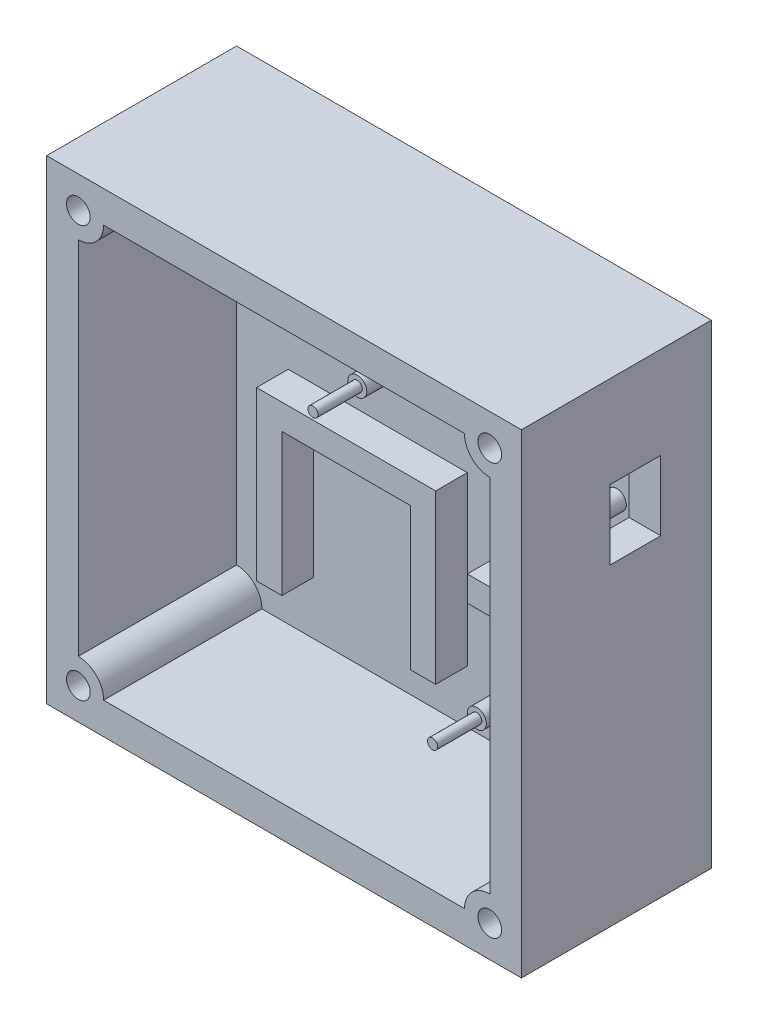
from build123d import *

# Parameters (mm, degrees)
SKETCH1_W           = 95.25
SKETCH1_H           = 95.25
BOSS_EXTRUDE1_DEPTH = 38.1
SHELL1_T            = -6.35
BOSS_EXTRUDE2_DEPTH = 31.75
SKETCH3_R           = 1.905
SKETCH3_R_2         = 1.016
BOSS_EXTRUDE3_DEPTH = 6.35
SKETCH4_R           = 1.016
BOSS_EXTRUDE4_DEPTH = 8.89
SKETCH5_R           = 1.905
SKETCH5_W           = 22.2885
SKETCH5_H           = 5.08
BOSS_EXTRUDE5_DEPTH = 6.35
SKETCH7_R           = 1.016
BOSS_EXTRUDE6_DEPTH = 8.89
SKETCH8_R           = 2.38125
CUT_EXTRUDE1_DEPTH  = 8.89
BOSS_EXTRUDE7_DEPTH = 6.35
SKETCH12_W          = 10.16
SKETCH12_H          = 13.97
CUT_EXTRUDE2_DEPTH  = 6.35


with BuildPart() as part:
    # Sketch1 → Boss-Extrude1 (new body)
    with BuildSketch(Plane.XY):
        Rectangle(SKETCH1_W, SKETCH1_H)
    extrude(amount=BOSS_EXTRUDE1_DEPTH)

    # Shell1
    shell1_openings = [part.faces().sort_by_distance(p)[0] for p in [
        (0, 0, 38.1),
    ]]
    offset(amount=SHELL1_T, openings=shell1_openings, kind=Kind.INTERSECTION)

    # Sketch2 → Boss-Extrude2 (add)
    with BuildSketch(Plane.XY.offset(38.1)):
        with BuildLine():
            Line((-41.275, 41.275), (-36.195, 41.275))
            ThreePointArc((-36.195, 41.275), (-37.682897552, 37.682897552), (-41.275, 36.195))
            Line((-41.275, 36.195), (-41.275, 41.275))
        make_face()
        with BuildLine():
            Line((36.195, 41.275), (41.275, 41.275))
            Line((41.275, 41.275), (41.275, 36.195))
            ThreePointArc((41.275, 36.195), (37.682897552, 37.682897552), (36.195, 41.275))
        make_face()
        with BuildLine():
            Line((41.275, -36.195), (41.275, -41.275))
            Line((41.275, -41.275), (36.195, -41.275))
            ThreePointArc((36.195, -41.275), (37.682897552, -37.682897552), (41.275, -36.195))
        make_face()
        with BuildLine():
            Line((-41.275, -36.195), (-41.275, -41.275))
            Line((-41.275, -41.275), (-36.195, -41.275))
            ThreePointArc((-36.195, -41.275), (-37.682897552, -37.682897552), (-41.275, -36.195))
        make_face()
    extrude(amount=-BOSS_EXTRUDE2_DEPTH)

    # Sketch3 → Boss-Extrude3 (add)
    with BuildSketch(Plane.XY.offset(6.35)):
        with Locations((35.015710728, 31.115)):
            Circle(SKETCH3_R)
        with Locations((-10.704289272, 31.115)):
            Circle(SKETCH3_R_2)
        with Locations((-10.704289272, 13.335)):
            Circle(SKETCH3_R)
        with Locations((35.015710728, 13.335)):
            Circle(SKETCH3_R)
    extrude(amount=BOSS_EXTRUDE3_DEPTH)

    # Sketch4 → Boss-Extrude4 (add)
    with BuildSketch(Plane.XY.offset(12.7)):
        with Locations((-10.704289272, 31.115)):
            Circle(SKETCH4_R)
        with Locations((-10.704289272, 13.335)):
            Circle(SKETCH4_R)
        with Locations((35.015710728, 31.115)):
            Circle(SKETCH4_R)
        with Locations((35.015710728, 13.335)):
            Circle(SKETCH4_R)
    extrude(amount=BOSS_EXTRUDE4_DEPTH)

    # Sketch5 → Boss-Extrude5 (add)
    with BuildSketch(Plane.XY.offset(6.35)):
        with Locations((13.2715, -32.385)):
            Circle(SKETCH5_R)
        with Locations((31.75, -32.385)):
            Circle(SKETCH5_R)
        with Locations((22.51075, -10.795)):
            Rectangle(SKETCH5_W, SKETCH5_H)
    extrude(amount=BOSS_EXTRUDE5_DEPTH)

    # Sketch7 → Boss-Extrude6 (add)
    with BuildSketch(Plane.XY.offset(12.7)):
        with Locations((13.2715, -32.385)):
            Circle(SKETCH7_R)
        with Locations((31.75, -32.385)):
            Circle(SKETCH7_R)
    extrude(amount=BOSS_EXTRUDE6_DEPTH)

    # Sketch8 → Cut-Extrude1 (cut)
    with BuildSketch(Plane.XY.offset(38.1)):
        with Locations((-41.275, 41.275)):
            Circle(SKETCH8_R)
        with Locations((41.275, 41.275)):
            Circle(SKETCH8_R)
        with Locations((41.275, -41.275)):
            Circle(SKETCH8_R)
        with Locations((-41.275, -41.275)):
            Circle(SKETCH8_R)
    extrude(amount=-CUT_EXTRUDE1_DEPTH, mode=Mode.SUBTRACT)

    # Sketch10 → Boss-Extrude7 (add)
    with BuildSketch(Plane.XY.offset(6.35)):
        Polygon((-30.8991, -30.607), (-30.8991, 2.9972), (5.0165, 2.9972), (5.0165, -30.607), (-0.0635, -30.607), (-0.0635, -2.0828), (-25.8191, -2.0828), (-25.8191, -30.607), align=None)
    extrude(amount=BOSS_EXTRUDE7_DEPTH)

    # Sketch12 → Cut-Extrude2 (cut)
    with BuildSketch(Plane(origin=(47.625, 0, 0), x_dir=(0, 0, -1), z_dir=(1, 0, 0))):
        with Locations((-15.24, 22.225)):
            Rectangle(SKETCH12_W, SKETCH12_H)
    extrude(amount=-CUT_EXTRUDE2_DEPTH, mode=Mode.SUBTRACT)


solid = part.part
